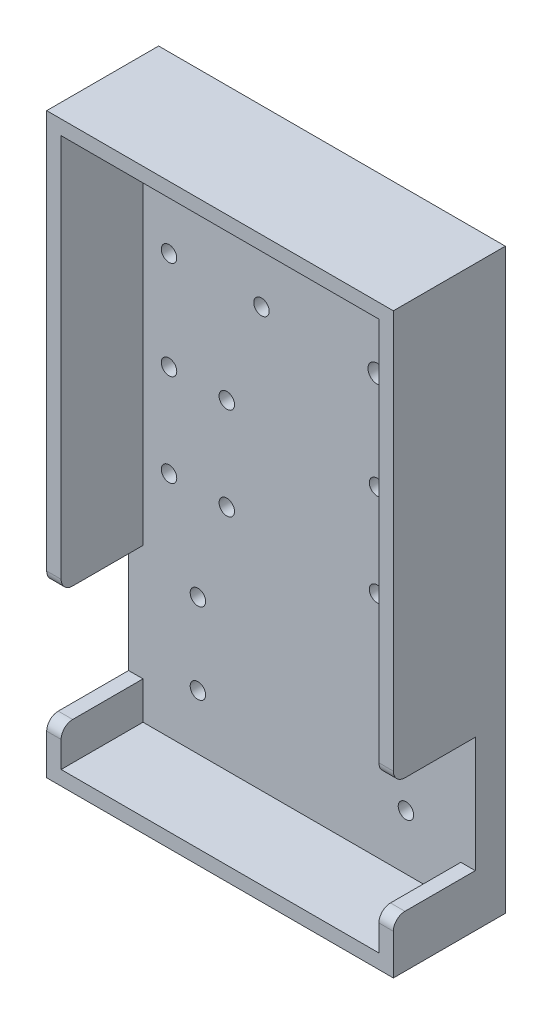
from build123d import *

# Parameters (mm, degrees)
SKETCH1_W           = 127
SKETCH1_H           = 76.2
BOSS_EXTRUDE1_DEPTH = 6.604
HOLE2_D             = 3.4
HOLE2_DEPTH         = 7
HOLE3_D             = 4
HOLE3_DEPTH         = 7
BOSS_EXTRUDE2_DEPTH = 18
FILLET1_R           = 2.54


with BuildPart() as part:
    # Sketch1 → Boss-Extrude1 (new body)
    with BuildSketch(Plane(origin=(0, 0, 0), x_dir=(0, 1, 0), z_dir=(0, 0, 1))):
        with Locations((63.5, -38.1)):
            Rectangle(SKETCH1_W, SKETCH1_H)
    extrude(amount=BOSS_EXTRUDE1_DEPTH)

    # Hole2
    with Locations(Plane.XY.offset(6.604)):
        with Locations((54.61, 73.66), (15.24, 15.24), (60.96, 15.24), (60.96, 33.02), (15.24, 33.02), (8.89, 53.34), (21.59, 53.34), (21.59, 73.66), (8.89, 73.66), (8.89, 95.25), (29.21, 95.25), (29.21, 115.57), (8.89, 115.57), (54.61, 53.34), (67.31, 53.34), (67.31, 73.66)):
            Hole(HOLE2_D / 2, depth=HOLE2_DEPTH)

    # Hole3
    with Locations(Plane.XY.offset(6.604)):
        with Locations((67.31, 115.57), (54.61, 115.57), (54.61, 95.25), (67.31, 95.25)):
            Hole(HOLE3_D / 2, depth=HOLE3_DEPTH)

    # Sketch12 → Boss-Extrude2 (add)
    with BuildSketch(Plane.XY.offset(6.604)):
        Polygon((3.175, 123.825), (3.175, 36.83), (0, 36.83), (0, 127), (76.2, 127), (76.2, 36.83), (73.025, 36.83), (73.025, 123.825), align=None)
        Polygon((0, 0), (76.2, 0), (76.2, 11.43), (73.025, 11.43), (73.025, 3.175), (3.175, 3.175), (3.175, 11.43), (0, 11.43), align=None)
    extrude(amount=BOSS_EXTRUDE2_DEPTH)

    # Fillet1
    fillet1_edges = [part.edges().sort_by_distance(p)[0] for p in [
        (1.5875, 36.83, 24.604),
        (74.6125, 36.83, 24.604),
        (74.6125, 11.43, 24.604),
        (1.5875, 11.43, 24.604),
    ]]
    fillet(fillet1_edges, radius=FILLET1_R)


solid = part.part
